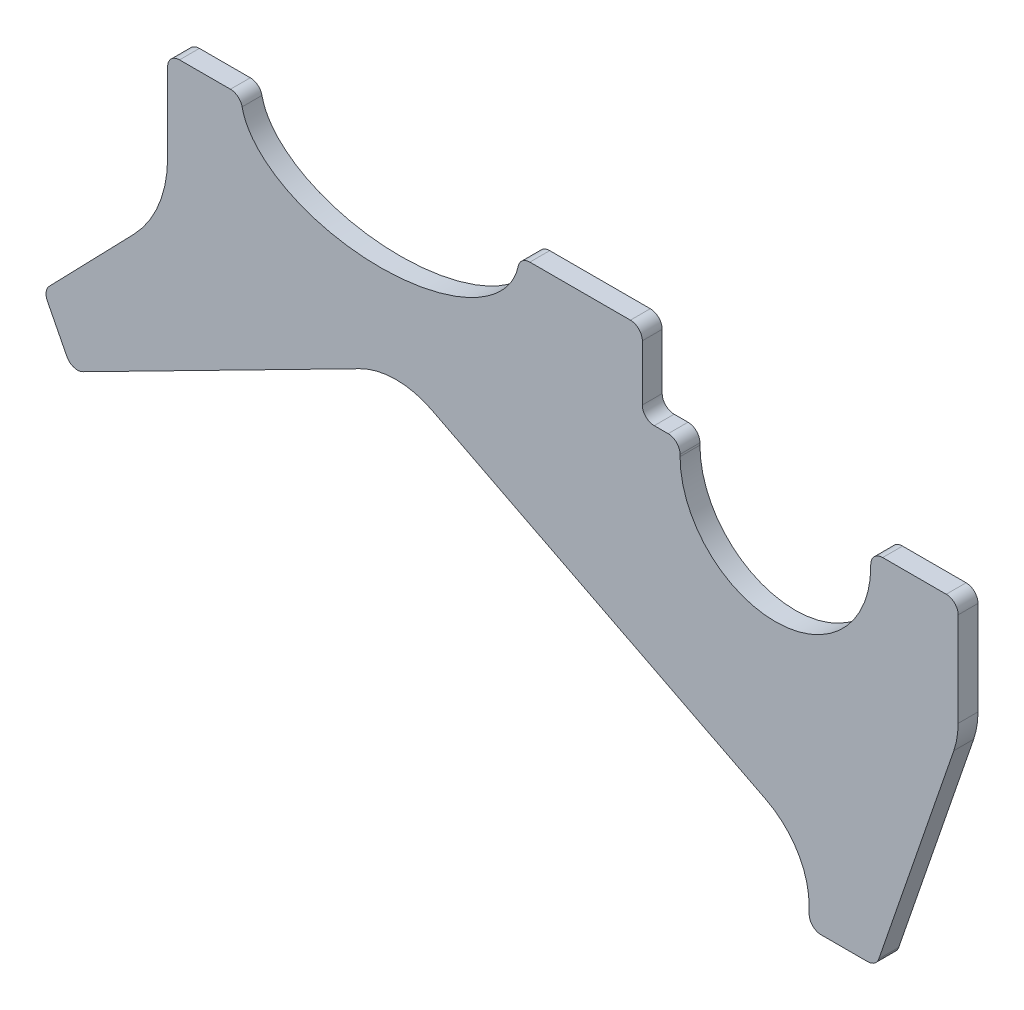
from build123d import *

# Parameters (mm, degrees)
EXTRUDE1_DEPTH = 5


with BuildPart() as part:
    # Sketch1 → Extrude1 (new body)
    with BuildSketch(Plane.XY):
        with BuildLine():
            Line((9.079809995, -4.626394269), (93.079809995, -47.426532026))
            ThreePointArc((93.079809995, -47.426532026), (101.052803287, -54.796691216), (104, -65.24666251))
            Line((104, -65.24666251), (104, -67))
            ThreePointArc((104, -67), (104.878679656, -69.121320344), (107, -70))
            Line((107, -70), (118.700463999, -70))
            ThreePointArc((118.700463999, -70), (120.442572866, -69.442346555), (121.537019726, -67.976704463))
            Line((121.537019726, -67.976704463), (140.410371512, -13.164510908))
            ThreePointArc((140.410371512, -13.164510908), (141.225712031, -9.954099936), (141.5, -6.653147818))
            Line((141.5, -6.653147818), (141.5, 17))
            ThreePointArc((141.5, 17), (140.621320344, 19.121320344), (138.5, 20))
            Line((138.5, 20), (122.5, 20))
            ThreePointArc((122.5, 20), (120.378679656, 19.121320344), (119.5, 17))
            Line((119.5, 17), (119.5, 16.5))
            ThreePointArc((119.5, 16.5), (95.5, -7.5), (71.5, 16.5))
            Line((71.5, 16.5), (71.5, 17))
            ThreePointArc((71.5, 17), (70.621320344, 19.121320344), (68.5, 20))
            Line((68.5, 20), (65, 20))
            ThreePointArc((65, 20), (62.878679656, 20.878679656), (62, 23))
            Line((62, 23), (62, 37))
            ThreePointArc((62, 37), (61.121320344, 39.121320344), (59, 40))
            Line((59, 40), (33.68653561, 40))
            ThreePointArc((33.68653561, 40), (31.795766306, 39.329161102), (30.750598067, 37.616660959))
            add(Edge.make_bspline(
                [(-38.750598067, 37.616660959), (-35.050414777, 20), (-4, 20), (27.050414777, 20), (30.750598067, 37.616660959)],
                knots=[3.261043467, 3.261043467, 3.261043467, 4.71238898, 4.71238898, 6.163734494, 6.163734494, 6.163734494], degree=2, weights=[1, 0.748053124, 1, 0.748053124, 1]))
            ThreePointArc((-38.750598067, 37.616660959), (-39.795766306, 39.329161102), (-41.68653561, 40))
            Line((-41.68653561, 40), (-54.5, 40))
            ThreePointArc((-54.5, 40), (-56.621320344, 39.121320344), (-57.5, 37))
            Line((-57.5, 37), (-57.5, 17.148970879))
            ThreePointArc((-57.5, 17.148970879), (-59.693566818, 5.888319313), (-65.953484912, -3.725599478))
            Line((-65.953484912, -3.725599478), (-87.272335061, -25.73069556))
            ThreePointArc((-87.272335061, -25.73069556), (-88.084372164, -27.372329), (-87.790703125, -29.180124095))
            Line((-87.790703125, -29.180124095), (-82.861971499, -38.853304561))
            ThreePointArc((-82.861971499, -38.853304561), (-81.11600291, -40.344502611), (-78.826980427, -40.164352635))
            Line((-78.826980427, -40.164352635), (-9.079809995, -4.626394269))
            ThreePointArc((-9.079809995, -4.626394269), (0, -2.446524753), (9.079809995, -4.626394269))
        make_face()
    extrude(amount=EXTRUDE1_DEPTH)


solid = part.part
